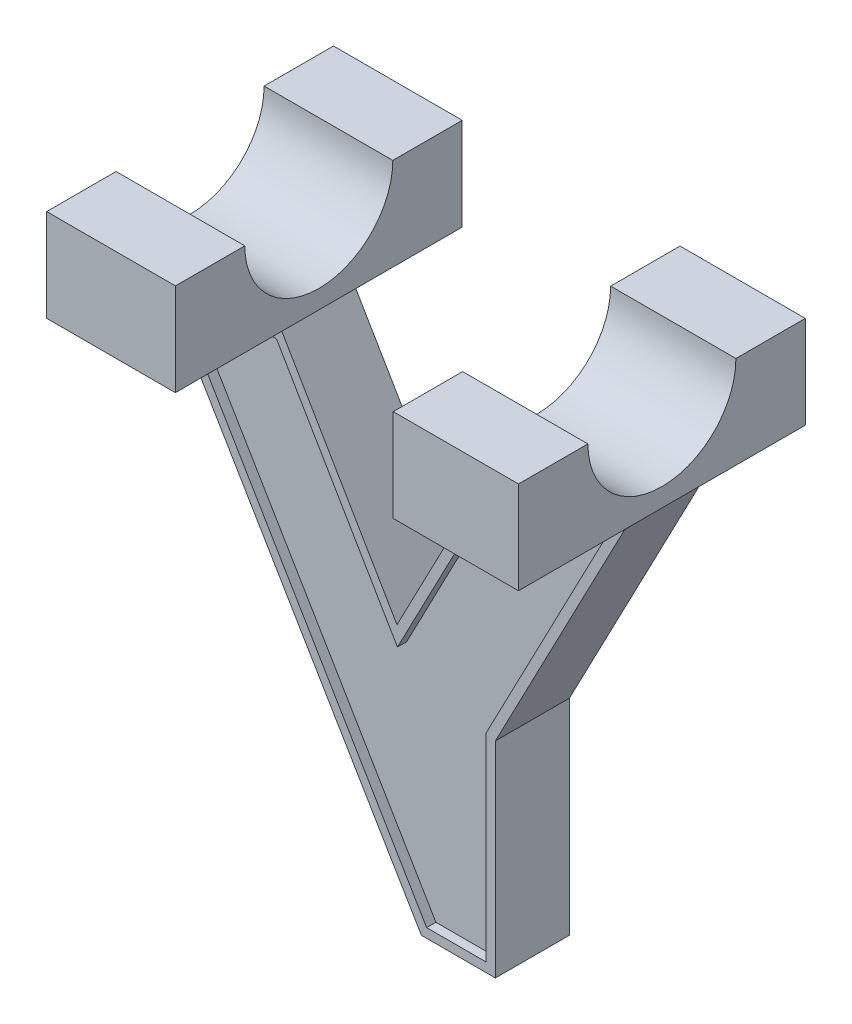
from build123d import *

# Parameters (mm, degrees)
SKETCH_1_W          = 51
SKETCH_1_H          = 31
EXTRUDE_1_DEPTH     = 10
SKETCH_2_R          = 8
CUT_EXTRUDE_1_DEPTH = 51
SKETCH_3_W          = 51
SKETCH_3_H          = 8
EXTRUDE_3_DEPTH     = 49
CUT_EXTRUDE_4_DEPTH = 49
CUT_EXTRUDE_5_DEPTH = 49
CUT_EXTRUDE_6_DEPTH = 1
CUT_EXTRUDE_7_DEPTH = 1


with BuildPart() as part:
    # Эскиз1 → Бобышка-Вытянуть1 (new body)
    with BuildSketch(Plane(origin=(0, 0, 0), x_dir=(1, 0, 0), z_dir=(0, 1, 0))):
        Rectangle(SKETCH_1_W, SKETCH_1_H)
    extrude(amount=EXTRUDE_1_DEPTH)

    # Эскиз2 → Вырез-Вытянуть1 (cut)
    with BuildSketch(Plane(origin=(25.5, 0, 0), x_dir=(0, 0, -1), z_dir=(1, 0, 0))):
        with Locations((0, 10)):
            Circle(SKETCH_2_R)
    extrude(amount=-CUT_EXTRUDE_1_DEPTH, mode=Mode.SUBTRACT)

    # Эскиз3 → Бобышка-Вытянуть3 (add)
    with BuildSketch(Plane.XZ):
        Rectangle(SKETCH_3_W, SKETCH_3_H)
    extrude(amount=EXTRUDE_3_DEPTH)

    # Эскиз4 → Вырез-Вытянуть4 (cut)
    with BuildSketch(Plane(origin=(0, 0, -4), x_dir=(-1, 0, 0), z_dir=(0, 0, -1))):
        Polygon((25.5, -49), (25.5, 0), (-3.5, -49), align=None)
        Polygon((-11.5, -26.802834127), (-25.5, 0), (-25.5, -49), (-11.5, -49), align=None)
        Polygon((11.587587539, 0), (-11.959179604, 0), (-0.863572713, -21.247079042), align=None)
    extrude(amount=-CUT_EXTRUDE_4_DEPTH, mode=Mode.SUBTRACT)

    # Эскиз6 → Вырез-Вытянуть5 (cut)
    with BuildSketch(Plane(origin=(0, 0, 0), x_dir=(-1, 0, 0), z_dir=(0, -1, 0))):
        Polygon((11.587587539, 4), (11.587587539, -15.5), (-11.959179604, -15.5), (-11.959179604, -4), (-11.959179604, 4), (-11.959179604, 15.5), (11.587587539, 15.5), align=None)
    extrude(amount=-CUT_EXTRUDE_5_DEPTH, mode=Mode.SUBTRACT)

    # Эскиз7 → Вырез-Вытянуть6 (cut)
    with BuildSketch(Plane(origin=(0, 0, -4), x_dir=(-1, 0, 0), z_dir=(0, 0, -1))):
        Polygon((23.746151768, -1), (12.160628495, -1), (-0.913951596, -23.310903643), (-12.56510683, -1), (-23.849468801, -1), (-10.5, -26.557399854), (-10.5, -48), (-4.070174763, -48), align=None)
    extrude(amount=-CUT_EXTRUDE_6_DEPTH, mode=Mode.SUBTRACT)

    # Эскиз8 → Вырез-Вытянуть7 (cut)
    with BuildSketch(Plane.XY.offset(4)):
        Polygon((12.56510683, -1), (0.913951596, -23.310903643), (-12.160628495, -1), (-23.746151768, -1), (4.070174763, -48), (10.5, -48), (10.5, -26.557399854), (23.849468801, -1), align=None)
    extrude(amount=-CUT_EXTRUDE_7_DEPTH, mode=Mode.SUBTRACT)


solid = part.part
